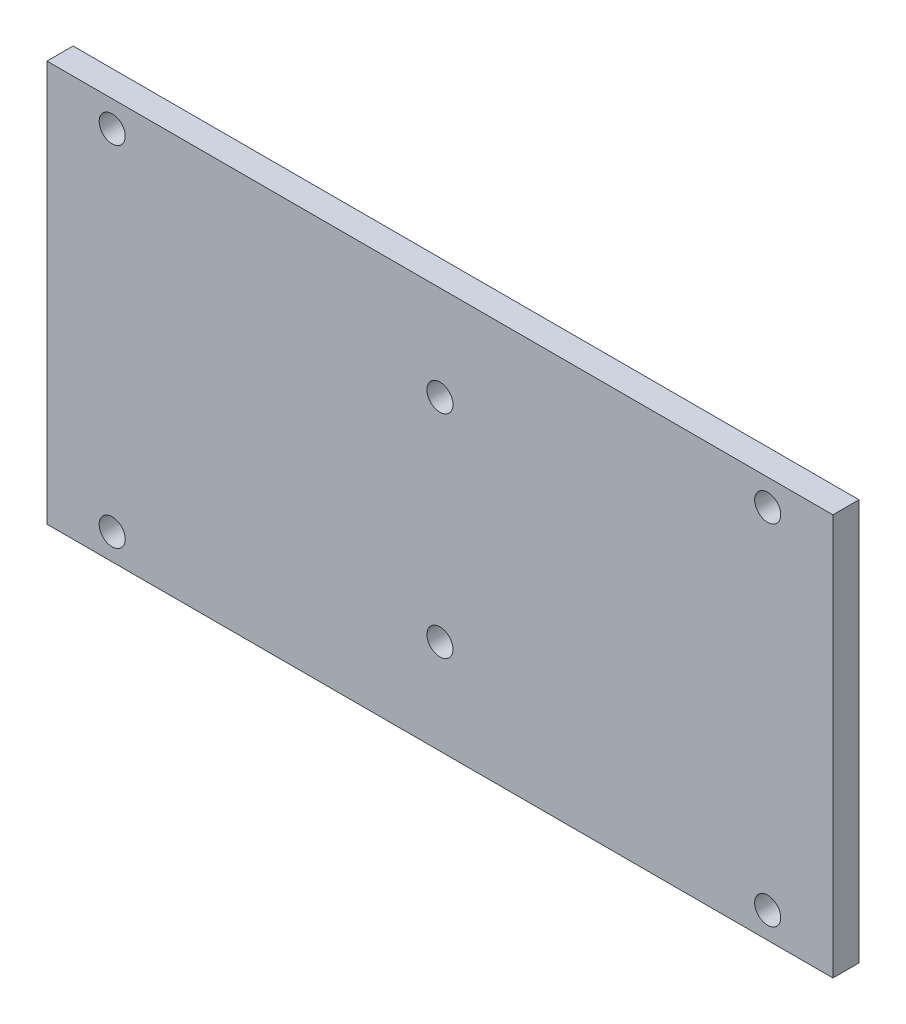
from build123d import *

# Parameters (mm, degrees)
CROQUIS1_W              = 120.5
CROQUIS1_H              = 61.5
CROQUIS1_R              = 2
SALIENTE_EXTRUIR1_DEPTH = 4


with BuildPart() as part:
    # Croquis1 → Saliente-Extruir1 (new body)
    with BuildSketch(Plane.XY):
        Rectangle(CROQUIS1_W, CROQUIS1_H)
        with Locations((-50.25, 26.75)):
            Circle(CROQUIS1_R, mode=Mode.SUBTRACT)
        with Locations((-50.25, -26.75)):
            Circle(CROQUIS1_R, mode=Mode.SUBTRACT)
        with Locations((50.25, -26.75)):
            Circle(CROQUIS1_R, mode=Mode.SUBTRACT)
        with Locations((50.25, 26.75)):
            Circle(CROQUIS1_R, mode=Mode.SUBTRACT)
        with Locations((0, 16.25)):
            Circle(CROQUIS1_R, mode=Mode.SUBTRACT)
        with Locations((0, -16.25)):
            Circle(CROQUIS1_R, mode=Mode.SUBTRACT)
    extrude(amount=SALIENTE_EXTRUIR1_DEPTH)


solid = part.part
